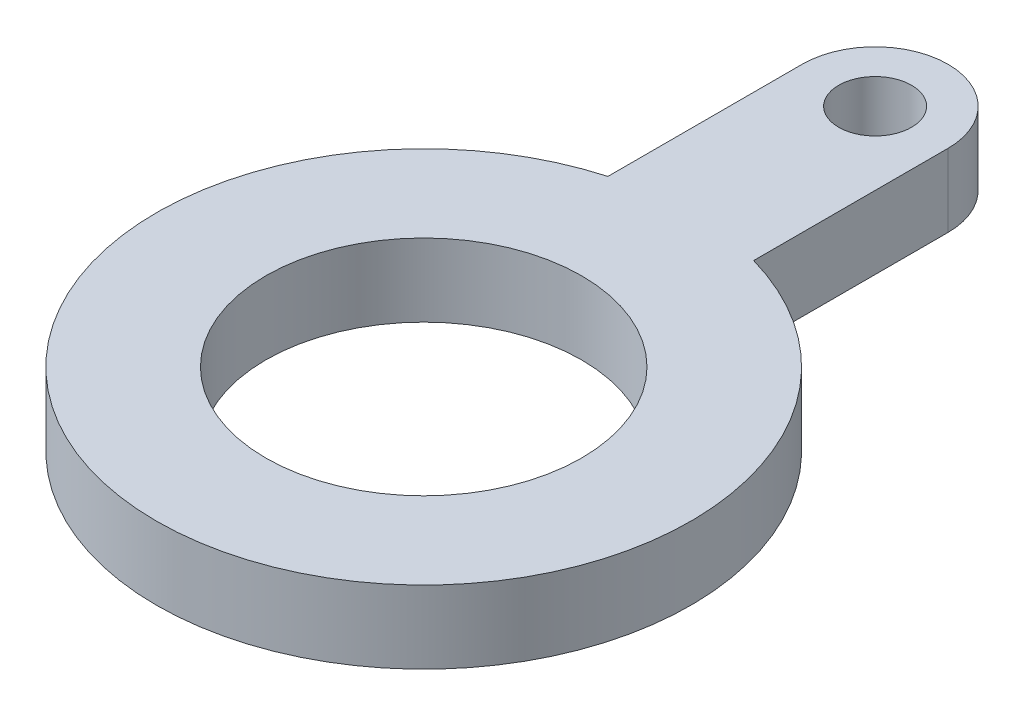
from build123d import *

# Parameters (mm, degrees)
SKETCH1_R           = 6.5
SKETCH1_R_2         = 1.5
BOSS_EXTRUDE1_DEPTH = 3


with BuildPart() as part:
    # Sketch1 → Boss-Extrude1 (new body)
    with BuildSketch(Plane(origin=(0, 0, 0), x_dir=(1, 0, 0), z_dir=(0, 1, 0))):
        with BuildLine():
            Line((3, 10.583005244), (3, 18.583005244))
            ThreePointArc((3, 18.583005244), (0, 21.583005244), (-3, 18.583005244))
            Line((-3, 18.583005244), (-3, 10.583005244))
            ThreePointArc((-3, 10.583005244), (0, -11), (3, 10.583005244))
        make_face()
        Circle(SKETCH1_R, mode=Mode.SUBTRACT)
        with Locations((0, 18.583005244)):
            Circle(SKETCH1_R_2, mode=Mode.SUBTRACT)
    extrude(amount=BOSS_EXTRUDE1_DEPTH)


solid = part.part
